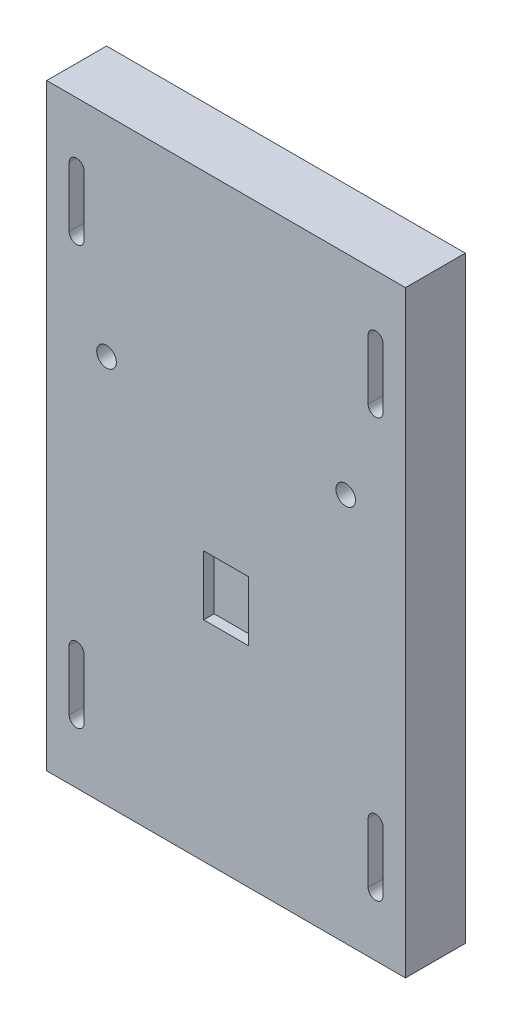
from build123d import *

# Parameters (mm, degrees)
SKETCH1_W           = 76.2
SKETCH1_H           = 127
BOSS_EXTRUDE1_DEPTH = 12.7
CUT_EXTRUDE1_DEPTH  = 6.35
CUT_EXTRUDE2_DEPTH  = 6.35
SKETCH4_W           = 9.525
SKETCH4_H           = 12.7
CUT_EXTRUDE3_DEPTH  = 2.2225
SKETCH5_R           = 2.0828
CUT_EXTRUDE4_DEPTH  = 25.4


with BuildPart() as part:
    # Sketch1 → Boss-Extrude1 (new body)
    with BuildSketch(Plane.XY):
        with Locations((38.1, 63.5)):
            Rectangle(SKETCH1_W, SKETCH1_H)
    extrude(amount=BOSS_EXTRUDE1_DEPTH)

    # Sketch2 → Cut-Extrude1 (cut)
    with BuildSketch(Plane.XY.offset(12.7)):
        with BuildLine():
            Line((71.4375, 12.7), (71.4375, 25.4))
            ThreePointArc((71.4375, 25.4), (69.85, 26.9875), (68.2625, 25.4))
            Line((68.2625, 25.4), (68.2625, 12.7))
            ThreePointArc((68.2625, 12.7), (69.85, 11.1125), (71.4375, 12.7))
        make_face()
        with BuildLine():
            Line((7.9375, 12.7), (7.9375, 25.4))
            ThreePointArc((7.9375, 25.4), (6.35, 26.9875), (4.7625, 25.4))
            Line((4.7625, 25.4), (4.7625, 12.7))
            ThreePointArc((4.7625, 12.7), (6.35, 11.1125), (7.9375, 12.7))
        make_face()
        with BuildLine():
            Line((7.9375, 101.6), (7.9375, 114.3))
            ThreePointArc((7.9375, 114.3), (6.35, 115.8875), (4.7625, 114.3))
            Line((4.7625, 114.3), (4.7625, 101.6))
            ThreePointArc((4.7625, 101.6), (6.35, 100.0125), (7.9375, 101.6))
        make_face()
        with BuildLine():
            Line((71.4375, 101.6), (71.4375, 114.3))
            ThreePointArc((71.4375, 114.3), (69.85, 115.8875), (68.2625, 114.3))
            Line((68.2625, 114.3), (68.2625, 101.6))
            ThreePointArc((68.2625, 101.6), (69.85, 100.0125), (71.4375, 101.6))
        make_face()
    extrude(amount=-CUT_EXTRUDE1_DEPTH, mode=Mode.SUBTRACT)

    # Sketch3 → Cut-Extrude2 (cut)
    with BuildSketch(Plane(origin=(0, 0, 0), x_dir=(-1, 0, 0), z_dir=(0, 0, -1))):
        with BuildLine():
            Line((-23.6855, 96.8375), (-10.9855, 96.8375))
            ThreePointArc((-10.9855, 96.8375), (-9.398, 98.425), (-10.9855, 100.0125))
            Line((-10.9855, 100.0125), (-23.6855, 100.0125))
            ThreePointArc((-23.6855, 100.0125), (-25.273, 98.425), (-23.6855, 96.8375))
        make_face()
        with BuildLine():
            Line((-65.0875, 96.8375), (-52.3875, 96.8375))
            ThreePointArc((-52.3875, 96.8375), (-50.8, 98.425), (-52.3875, 100.0125))
            Line((-52.3875, 100.0125), (-65.0875, 100.0125))
            ThreePointArc((-65.0875, 100.0125), (-66.675, 98.425), (-65.0875, 96.8375))
        make_face()
        with BuildLine():
            Line((-65.0875, 26.9875), (-52.3875, 26.9875))
            ThreePointArc((-52.3875, 26.9875), (-50.8, 28.575), (-52.3875, 30.1625))
            Line((-52.3875, 30.1625), (-65.0875, 30.1625))
            ThreePointArc((-65.0875, 30.1625), (-66.675, 28.575), (-65.0875, 26.9875))
        make_face()
        with BuildLine():
            Line((-23.6855, 26.9875), (-10.9855, 26.9875))
            ThreePointArc((-10.9855, 26.9875), (-9.398, 28.575), (-10.9855, 30.1625))
            Line((-10.9855, 30.1625), (-23.6855, 30.1625))
            ThreePointArc((-23.6855, 30.1625), (-25.273, 28.575), (-23.6855, 26.9875))
        make_face()
    extrude(amount=-CUT_EXTRUDE2_DEPTH, mode=Mode.SUBTRACT)

    # Sketch4 → Cut-Extrude3 (cut)
    with BuildSketch(Plane.XY.offset(12.7)):
        with Locations((38.1, 50.8)):
            Rectangle(SKETCH4_W, SKETCH4_H)
    extrude(amount=-CUT_EXTRUDE3_DEPTH, mode=Mode.SUBTRACT)

    # Sketch5 → Cut-Extrude4 (cut)
    with BuildSketch(Plane.XY.offset(12.7)):
        with Locations((12.7, 82.55)):
            Circle(SKETCH5_R)
        with Locations((63.5, 82.55)):
            Circle(SKETCH5_R)
    extrude(amount=-CUT_EXTRUDE4_DEPTH, mode=Mode.SUBTRACT)


solid = part.part
